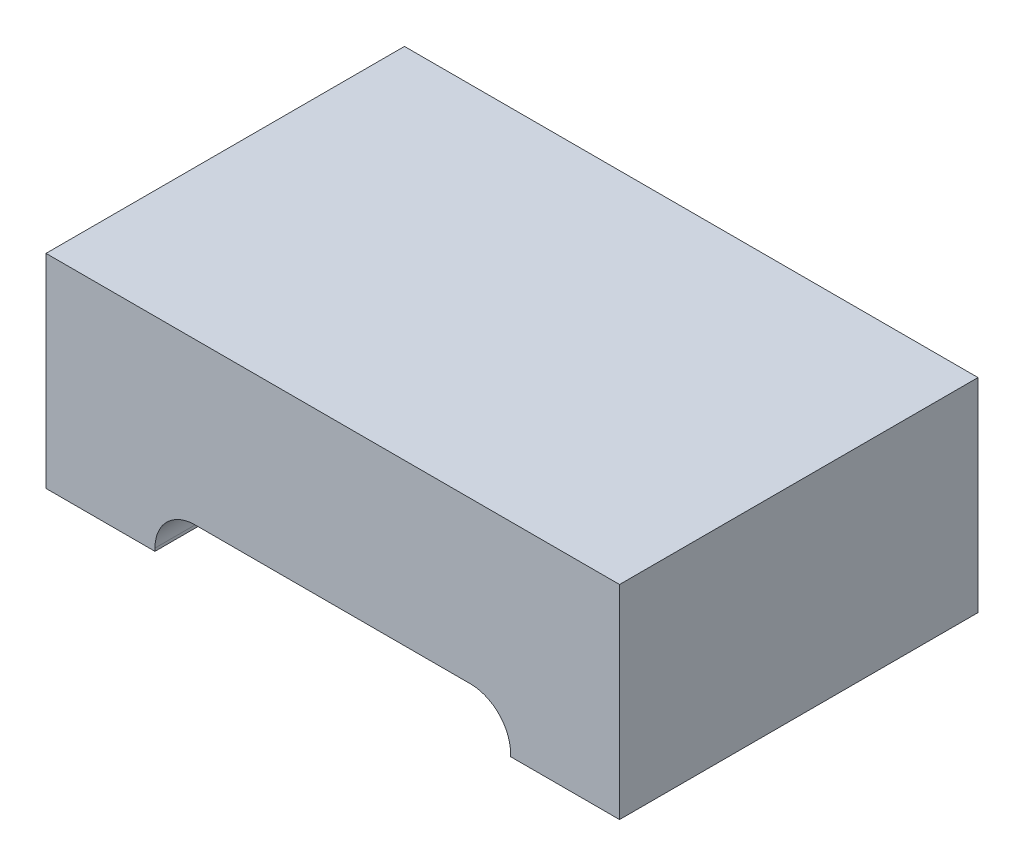
from build123d import *

# Parameters (mm, degrees)
SKETCH1_W               = 2
SKETCH1_H               = 1.25
BOSS_EXTRUDE1_DEPTH     = 0.71
CUT_EXTRUDE1_DEPTH      = 1.625
CUT_EXTRUDE1_DEPTH_BACK = 1.625


with BuildPart() as part:
    # Sketch1 → Boss-Extrude1 (new body)
    with BuildSketch(Plane(origin=(0, 0, 0), x_dir=(1, 0, 0), z_dir=(0, 1, 0))):
        Rectangle(SKETCH1_W, SKETCH1_H)
    extrude(amount=BOSS_EXTRUDE1_DEPTH)

    # Sketch2 → Cut-Extrude1 (cut, two sides)
    with BuildSketch(Plane.XY) as cut_extrude1_sk:
        with BuildLine():
            Line((-0.62, 0), (0.62, 0))
            Line((0.62, 0), (0.62, 0.01))
            ThreePointArc((0.62, 0.01), (0.578994949, 0.108994949), (0.48, 0.15))
            Line((0.48, 0.15), (-0.48, 0.15))
            ThreePointArc((-0.48, 0.15), (-0.578994949, 0.108994949), (-0.62, 0.01))
            Line((-0.62, 0.01), (-0.62, 0))
        make_face()
    extrude(amount=CUT_EXTRUDE1_DEPTH, mode=Mode.SUBTRACT)
    extrude(cut_extrude1_sk.sketch, amount=-CUT_EXTRUDE1_DEPTH_BACK, mode=Mode.SUBTRACT)


solid = part.part
